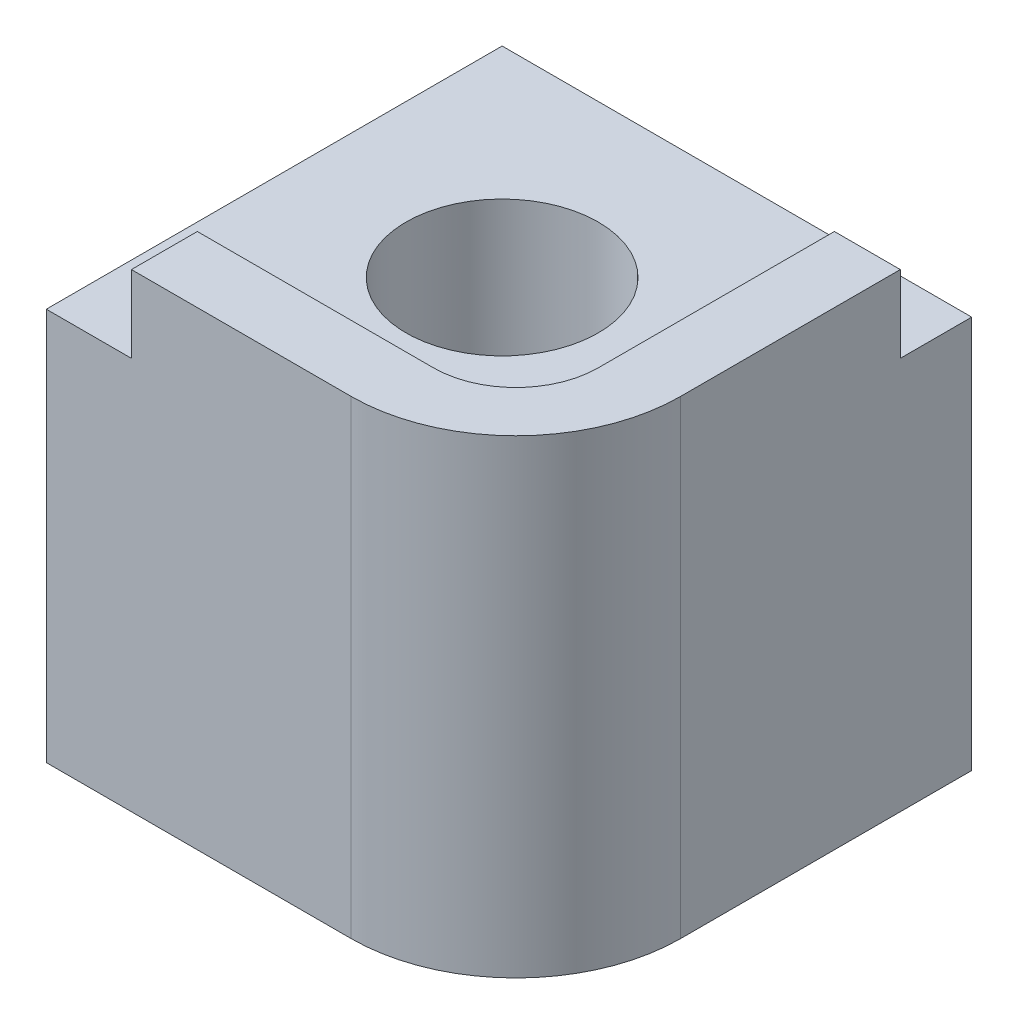
from build123d import *

# Parameters (mm, degrees)
SKETCH1_W           = 8.55
SKETCH1_H           = 8.55
BOSS_EXTRUDE1_DEPTH = 8.3
SKETCH2_W           = 1.55
SKETCH2_H           = 1.4
CUT_EXTRUDE1_DEPTH  = 9.3
SKETCH3_W           = 1.3
SKETCH3_H           = 1.4
CUT_EXTRUDE2_DEPTH  = 9.55
SKETCH4_W           = 5.8
SKETCH4_H           = 5.8
CUT_EXTRUDE3_DEPTH  = 1.4
FILLET1_R           = 1.5
FILLET2_R           = 3
SKETCH5_R           = 1.75
CUT_EXTRUDE4_DEPTH  = 9.55
CHAMFER1_SIZE       = 0.5
CHAMFER1_SIZE2      = 0.350103769


with BuildPart() as part:
    # Sketch1 → Boss-Extrude1 (new body)
    with BuildSketch(Plane.XY):
        with Locations((4.275, 4.275)):
            Rectangle(SKETCH1_W, SKETCH1_H)
    extrude(amount=BOSS_EXTRUDE1_DEPTH)

    # Sketch2 → Cut-Extrude1 (cut, through all)
    with BuildSketch(Plane.XY.offset(8.3)):
        with Locations((0.775, 7.85)):
            Rectangle(SKETCH2_W, SKETCH2_H)
    extrude(amount=-CUT_EXTRUDE1_DEPTH, mode=Mode.SUBTRACT)

    # Sketch3 → Cut-Extrude2 (cut, through all)
    with BuildSketch(Plane(origin=(8.55, 0, 0), x_dir=(0, 0, -1), z_dir=(1, 0, 0))):
        with Locations((-0.65, 7.85)):
            Rectangle(SKETCH3_W, SKETCH3_H)
    extrude(amount=-CUT_EXTRUDE2_DEPTH, mode=Mode.SUBTRACT)

    # Sketch4 → Cut-Extrude3 (cut)
    with BuildSketch(Plane(origin=(0, 8.55, 0), x_dir=(1, 0, 0), z_dir=(0, 1, 0))):
        with Locations((4.45, -4.2)):
            Rectangle(SKETCH4_W, SKETCH4_H)
    extrude(amount=-CUT_EXTRUDE3_DEPTH, mode=Mode.SUBTRACT)

    # Fillet1
    fillet1_edges = [part.edges().sort_by_distance(p)[0] for p in [
        (7.35, 7.85, 7.1),
    ]]
    fillet(fillet1_edges, radius=FILLET1_R)

    # Fillet2
    fillet2_edges = [part.edges().sort_by_distance(p)[0] for p in [
        (8.55, 4.275, 8.3),
    ]]
    fillet(fillet2_edges, radius=FILLET2_R)

    # Sketch5 → Cut-Extrude4 (cut, through all)
    with BuildSketch(Plane.XZ):
        with Locations((3.65, 3.65)):
            Circle(SKETCH5_R)
    extrude(amount=-CUT_EXTRUDE4_DEPTH, mode=Mode.SUBTRACT)

    # Chamfer1
    chamfer1_edges = [part.edges().sort_by_distance(p)[0] for p in [
        (1.9, 0, 3.65),
    ]]
    chamfer1_side = [part.faces().sort_by_distance(p)[0] for p in [
        (8.430839394, 0, 2.65),
    ]]
    chamfer(chamfer1_edges, length=CHAMFER1_SIZE, length2=CHAMFER1_SIZE2, reference=chamfer1_side[0])


solid = part.part
